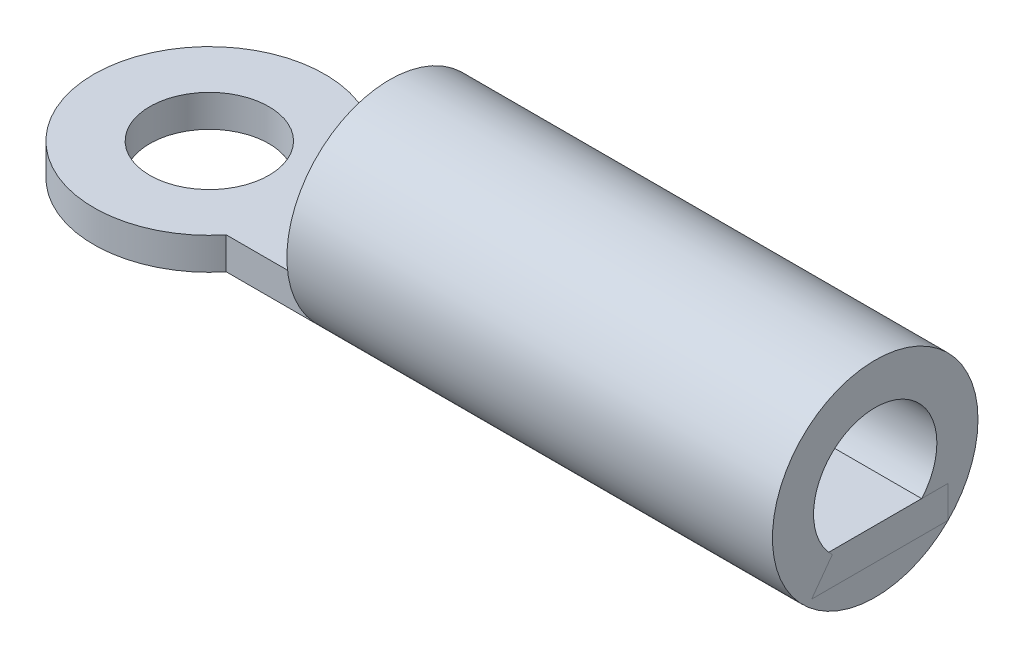
from build123d import *

# Parameters (mm, degrees)
SKIZZE1_R                       = 1.84
AUFSATZ_LINEAR_AUSTRAGEN1_DEPTH = 0.99
SKIZZE2_R                       = 3.175
SKIZZE2_R_2                     = 1.905
AUFSATZ_LINEAR_AUSTRAGEN2_DEPTH = 15


with BuildPart() as part:
    # Skizze1 → Aufsatz-Linear austragen1 (new body)
    with BuildSketch(Plane(origin=(0, 0, 0), x_dir=(1, 0, 0), z_dir=(0, 1, 0))):
        with BuildLine():
            Line((2.771714271, 2.25), (20.57, 2.25))
            Line((20.57, 2.25), (20.57, -2.25))
            Line((20.57, -2.25), (2.771714271, -2.25))
            ThreePointArc((2.771714271, -2.25), (-3.57, 0), (2.771714271, 2.25))
        make_face()
        Circle(SKIZZE1_R, mode=Mode.SUBTRACT)
    extrude(amount=AUFSATZ_LINEAR_AUSTRAGEN1_DEPTH)


with BuildPart() as body_2:
    # Skizze2 → Aufsatz-Linear austragen2 (new body)
    with BuildSketch(Plane(origin=(20.57, 0, 0), x_dir=(0, 0, -1), z_dir=(1, 0, 0))):
        with Locations((0, 2.240117184)):
            Circle(SKIZZE2_R)
        with Locations((0, 2.240117184)):
            Circle(SKIZZE2_R_2, mode=Mode.SUBTRACT)
    extrude(amount=-AUFSATZ_LINEAR_AUSTRAGEN2_DEPTH)


solid = Compound([part.part, body_2.part])
